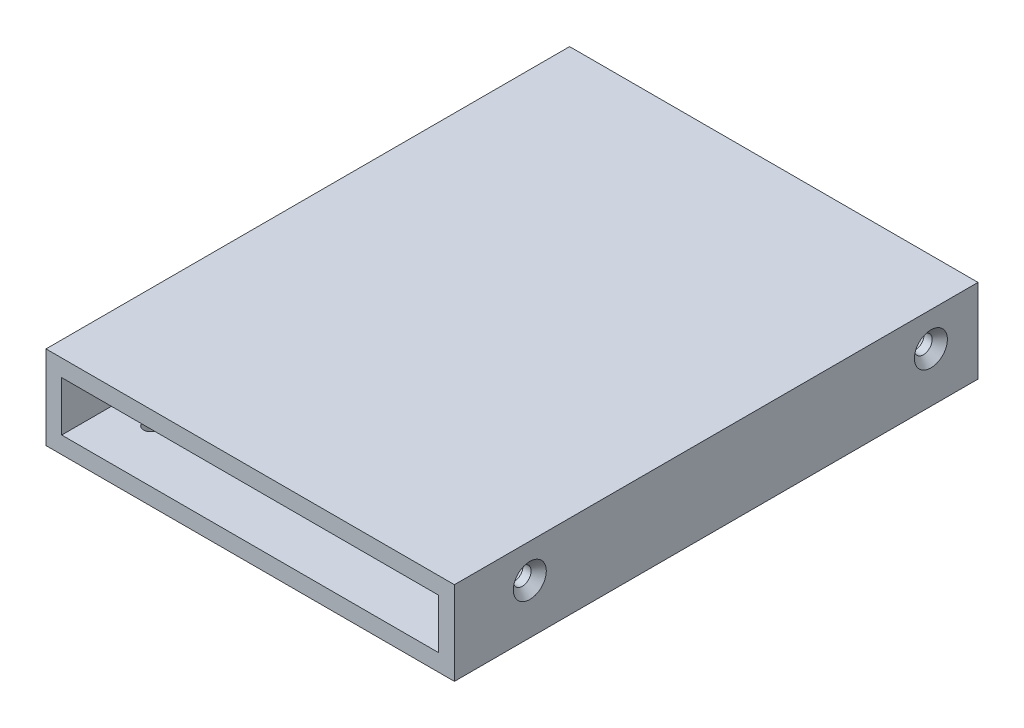
from build123d import *

# Parameters (mm, degrees)
MAIN_SKETCH_W                                  = 78
MAIN_SKETCH_H                                  = 16
MAIN_SKETCH_W_2                                = 72
MAIN_SKETCH_H_2                                = 9.5
MAIN_EXTRUSION_DEPTH                           = 100
FRAISAGE_POUR_VIS_T_TE_FRAIS_E_M31_D           = 3.4
FRAISAGE_POUR_VIS_T_TE_FRAIS_E_M31_CSINK_D     = 6.3
FRAISAGE_POUR_VIS_T_TE_FRAIS_E_M31_CSINK_ANGLE = 90
R_P_TITION_LIN_AIRE1_COUNT                     = 2
R_P_TITION_LIN_AIRE1_PITCH                     = 76.6
FRAISAGE_POUR_VIS_T_TE_FRAIS_E_M32_D           = 3.4
FRAISAGE_POUR_VIS_T_TE_FRAIS_E_M32_CSINK_D     = 6.3
FRAISAGE_POUR_VIS_T_TE_FRAIS_E_M32_CSINK_ANGLE = 90
R_P_TITION_LIN_AIRE3_COUNT                     = 2
R_P_TITION_LIN_AIRE3_PITCH                     = 76.5
FRAISAGE_POUR_VIS_T_TE_FRAIS_E_M33_D           = 3.4
FRAISAGE_POUR_VIS_T_TE_FRAIS_E_M33_CSINK_D     = 6.3
FRAISAGE_POUR_VIS_T_TE_FRAIS_E_M33_CSINK_ANGLE = 90
SUPPORT_FIX_HOLE_REACH                         = 18
SUPPORT_FIX_SKETCH_R                           = 1.35


with BuildPart() as part:
    # Main-Sketch → Main-Extrusion (new body)
    with BuildSketch(Plane.XY):
        with Locations((39, 8)):
            Rectangle(MAIN_SKETCH_W, MAIN_SKETCH_H)
        with Locations((39, 8)):
            Rectangle(MAIN_SKETCH_W_2, MAIN_SKETCH_H_2, mode=Mode.SUBTRACT)
    extrude(amount=MAIN_EXTRUSION_DEPTH)

    # Fraisage pour vis à tête fraisée M31 (through all)
    with Locations(Plane.ZY):
        with Locations((9, 9.5)):
            fraisage_pour_vis_t_te_frais_e_m31 = CounterSinkHole(FRAISAGE_POUR_VIS_T_TE_FRAIS_E_M31_D / 2, FRAISAGE_POUR_VIS_T_TE_FRAIS_E_M31_CSINK_D / 2, counter_sink_angle=FRAISAGE_POUR_VIS_T_TE_FRAIS_E_M31_CSINK_ANGLE)

    # Répétition linéaire1: Fraisage pour vis à tête fraisée M31 ×2
    with Locations(*[(0, 0, i * R_P_TITION_LIN_AIRE1_PITCH) for i in range(1, R_P_TITION_LIN_AIRE1_COUNT)]):
        add(fraisage_pour_vis_t_te_frais_e_m31, mode=Mode.SUBTRACT)

    # Fraisage pour vis à tête fraisée M32 (through all)
    with Locations(Plane(origin=(78, 0, 0), x_dir=(0, 0, -1), z_dir=(1, 0, 0))):
        with Locations((-85.6, 9.5)):
            fraisage_pour_vis_t_te_frais_e_m32 = CounterSinkHole(FRAISAGE_POUR_VIS_T_TE_FRAIS_E_M32_D / 2, FRAISAGE_POUR_VIS_T_TE_FRAIS_E_M32_CSINK_D / 2, counter_sink_angle=FRAISAGE_POUR_VIS_T_TE_FRAIS_E_M32_CSINK_ANGLE)

    # Répétition linéaire3: Fraisage pour vis à tête fraisée M32 ×2
    with Locations(*[(i * R_P_TITION_LIN_AIRE3_PITCH, 0, 0) for i in range(1, R_P_TITION_LIN_AIRE3_COUNT)]):
        add(fraisage_pour_vis_t_te_frais_e_m32, mode=Mode.SUBTRACT)

    # Fraisage pour vis à tête fraisée M33 (through all)
    with Locations(Plane(origin=(78, 0, 0), x_dir=(0, 0, -1), z_dir=(1, 0, 0))):
        with Locations((-9, 9.5)):
            CounterSinkHole(FRAISAGE_POUR_VIS_T_TE_FRAIS_E_M33_D / 2, FRAISAGE_POUR_VIS_T_TE_FRAIS_E_M33_CSINK_D / 2, counter_sink_angle=FRAISAGE_POUR_VIS_T_TE_FRAIS_E_M33_CSINK_ANGLE)

    # Support-Fix-Sketch → Support-Fix-Hole (cut, up to next)
    with BuildSketch(Plane.XZ, mode=Mode.PRIVATE) as support_fix_hole_sk1:
        with Locations((68, 90)):
            Circle(SUPPORT_FIX_SKETCH_R)
    support_fix_hole_tool1 = extrude(support_fix_hole_sk1.sketch, amount=-SUPPORT_FIX_HOLE_REACH, mode=Mode.PRIVATE) & part.part
    add(support_fix_hole_tool1.solids().sort_by_distance((68, 0, 90))[0], mode=Mode.SUBTRACT)
    # Support-Fix-Sketch → Support-Fix-Hole (cut, up to next)
    with BuildSketch(Plane.XZ, mode=Mode.PRIVATE) as support_fix_hole_sk2:
        with Locations((68, 10)):
            Circle(SUPPORT_FIX_SKETCH_R)
    support_fix_hole_tool2 = extrude(support_fix_hole_sk2.sketch, amount=-SUPPORT_FIX_HOLE_REACH, mode=Mode.PRIVATE) & part.part
    add(support_fix_hole_tool2.solids().sort_by_distance((68, 0, 10))[0], mode=Mode.SUBTRACT)
    # Support-Fix-Sketch → Support-Fix-Hole (cut, up to next)
    with BuildSketch(Plane.XZ, mode=Mode.PRIVATE) as support_fix_hole_sk3:
        with Locations((10, 10)):
            Circle(SUPPORT_FIX_SKETCH_R)
    support_fix_hole_tool3 = extrude(support_fix_hole_sk3.sketch, amount=-SUPPORT_FIX_HOLE_REACH, mode=Mode.PRIVATE) & part.part
    add(support_fix_hole_tool3.solids().sort_by_distance((10, 0, 10))[0], mode=Mode.SUBTRACT)
    # Support-Fix-Sketch → Support-Fix-Hole (cut, up to next)
    with BuildSketch(Plane.XZ, mode=Mode.PRIVATE) as support_fix_hole_sk4:
        with Locations((10, 90)):
            Circle(SUPPORT_FIX_SKETCH_R)
    support_fix_hole_tool4 = extrude(support_fix_hole_sk4.sketch, amount=-SUPPORT_FIX_HOLE_REACH, mode=Mode.PRIVATE) & part.part
    add(support_fix_hole_tool4.solids().sort_by_distance((10, 0, 90))[0], mode=Mode.SUBTRACT)


solid = part.part
